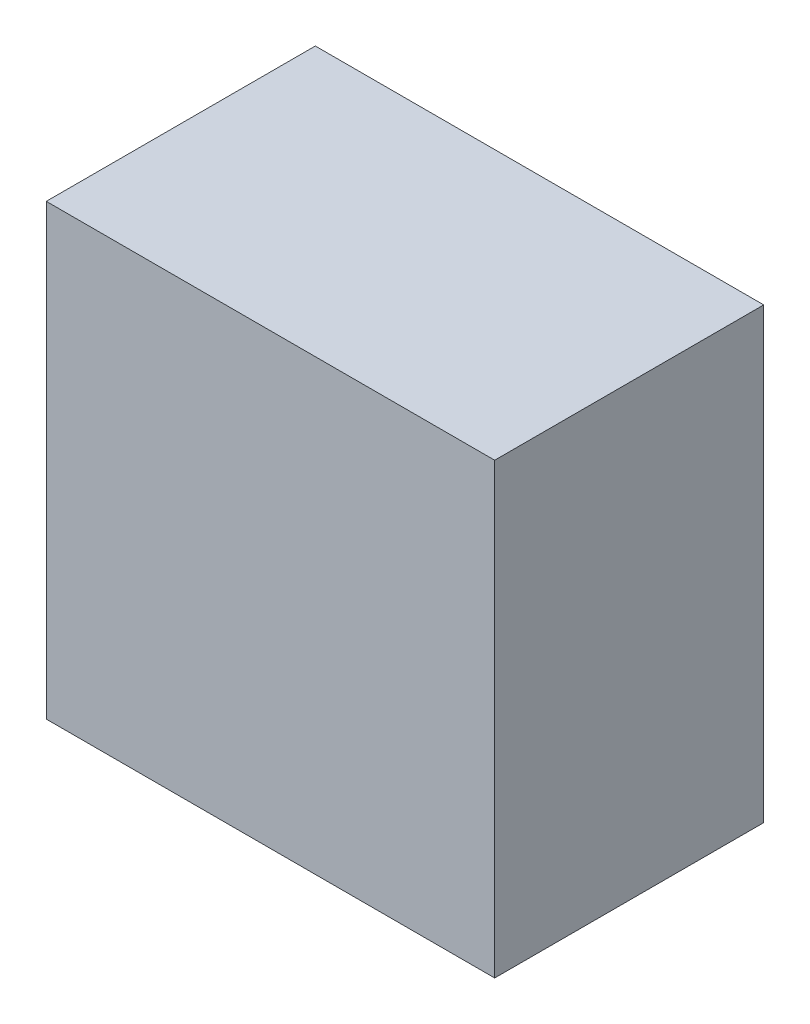
from build123d import *

# Parameters (mm, degrees)
SKETCH_1_W          = 20
SKETCH_1_H          = 20
EXTRUDE_1_DEPTH     = 12
SKETCH_2_W          = 18
SKETCH_2_H          = 18
CUT_EXTRUDE_1_DEPTH = 10


with BuildPart() as part:
    # 草圖1 → 填料-伸長1 (new body)
    with BuildSketch(Plane.XY):
        Rectangle(SKETCH_1_W, SKETCH_1_H)
    extrude(amount=EXTRUDE_1_DEPTH)

    # 草圖2 → 除料-伸長1 (cut)
    with BuildSketch(Plane(origin=(0, 0, 0), x_dir=(-1, 0, 0), z_dir=(0, 0, -1))):
        Rectangle(SKETCH_2_W, SKETCH_2_H)
    extrude(amount=-CUT_EXTRUDE_1_DEPTH, mode=Mode.SUBTRACT)


solid = part.part
